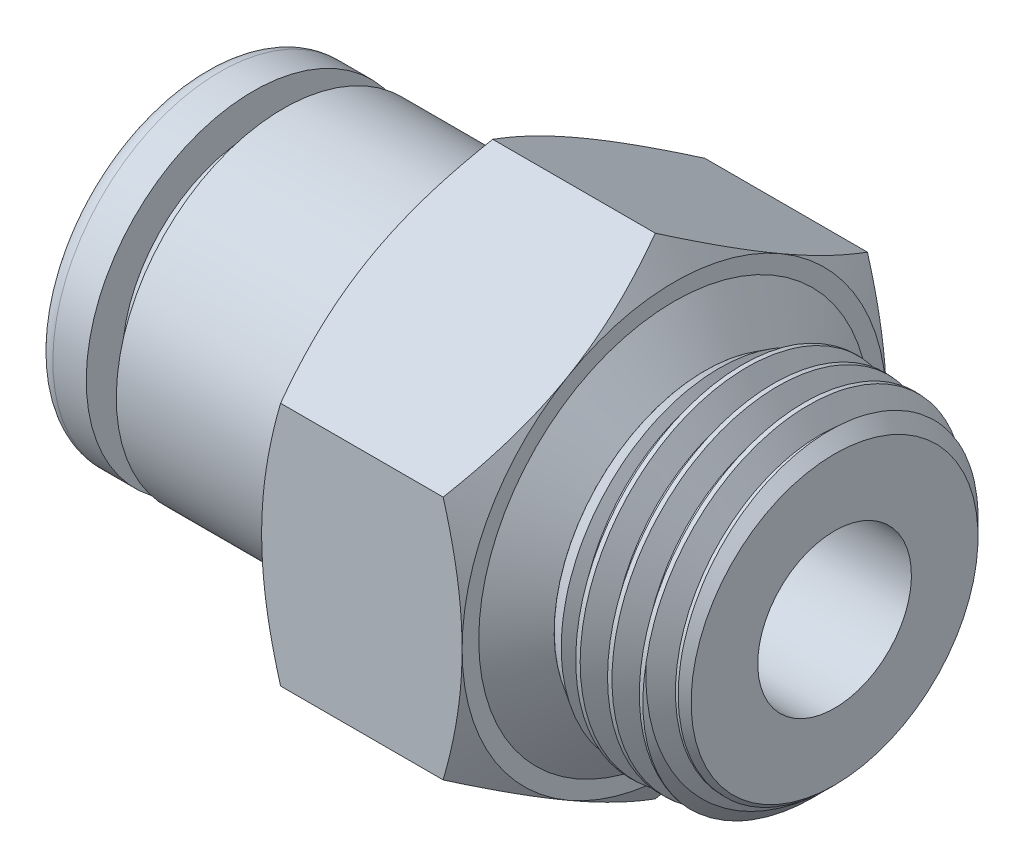
from build123d import *

# Parameters (mm, degrees)
SKETCH2_R              = 5.1435
EXTRUDE1_DEPTH         = 4.8
EXTRUDE1_TAPER         = 1.783333333
SKETCH5_OUTSIDE_W      = 26.658
SKETCH5_OUTSIDE_H      = 26.658
SKETCH5_OUTSIDE_R      = 4.294145567
EXTRUDE2_DEPTH         = 4.8
EXTRUDE2_DRAFT         = -45
CUT_SWEEP1_PITCH       = 0.924083939
CUT_SWEEP1_HEIGHT      = 5.723636364
CUT_SWEEP1_RADIUS      = 4.994051553
CUT_SWEEP1_START_ANGLE = -90
SKETCH6_R              = 5.1435
EXTRUDE3_DEPTH         = 3
EXTRUDE3_DRAFT         = -45
SKETCH7_R              = 2.3
EXTRUDE4_DEPTH         = 21.251448948
SKETCH8_R              = 5
EXTRUDE5_DEPTH         = 6
SKETCH9_OUTSIDE_W      = 40.902
SKETCH9_OUTSIDE_H      = 42.866
SKETCH9_OUTSIDE_R      = 6.35
EXTRUDE6_DEPTH         = 6
EXTRUDE6_DRAFT         = -60
SKETCH10_OUTSIDE_W     = 40.902
SKETCH10_OUTSIDE_H     = 42.866
SKETCH10_OUTSIDE_R     = 6.35
EXTRUDE7_DEPTH         = 6
EXTRUDE7_DRAFT         = -60


with BuildPart() as part:
    # Sketch1 → Revolve2 (revolve)
    with BuildSketch(Plane(origin=(0, 0, 0), x_dir=(-1, 0, 0), z_dir=(0, 0, -1)), mode=Mode.PRIVATE) as revolve2_sk:
        with BuildLine():
            Line((0, 4.5), (0, 3.675))
            ThreePointArc((0, 3.675), (-0.146446609, 3.321446609), (-0.5, 3.175))
            Line((-0.5, 3.175), (-9.45, 3.175))
            Line((-9.45, 3.175), (-9.45, 0))
            Line((-9.45, 0), (-14.1, 0))
            Line((-14.1, 0), (-14.1, 5))
            Line((-14.1, 5), (-2.4, 5))
            Line((-2.4, 5), (-2.4, 3.925))
            Line((-2.4, 3.925), (-1.5, 3.925))
            Line((-1.5, 3.925), (-1.5, 5))
            Line((-1.5, 5), (-0.5, 5))
            ThreePointArc((-0.5, 5), (-0.146446609, 4.853553391), (0, 4.5))
        make_face()
    revolve(revolve2_sk.sketch.rotate(Axis((0, 0, 0), (1, 0, 0)), 180), axis=Axis((0, 0, 0), (1, 0, 0)))


with BuildPart() as body_2:
    # Sketch2 → Extrude1 (new body)
    with BuildSketch(Plane(origin=(14.1, 0, 0), x_dir=(0, 0, -1), z_dir=(1, 0, 0))):
        Circle(SKETCH2_R)
    extrude(amount=EXTRUDE1_DEPTH, taper=EXTRUDE1_TAPER)


with BuildPart() as extrude2_tool:
    # Sketch5 outside → Extrude2 (with draft: the straight prism first)
    with BuildSketch(Plane(origin=(18.9, 0, 0), x_dir=(0, 0, -1), z_dir=(1, 0, 0))):
        Rectangle(SKETCH5_OUTSIDE_W, SKETCH5_OUTSIDE_H)
        Circle(SKETCH5_OUTSIDE_R, mode=Mode.SUBTRACT)
    extrude(amount=-EXTRUDE2_DEPTH)
    # Extrude2: the draft: its side faces are tilted about the plane it starts from
    extrude2_sides = [extrude2_tool.faces().sort_by_distance(p)[0] for p in [
        (16.5, -13.329, 0),
        (16.5, 0, -13.329),
        (16.5, 13.329, 0),
        (16.5, 0, 13.329),
        (16.5, 0, 4.294145567),
    ]]
    draft(extrude2_sides, Plane(origin=(18.9, 0, 0), x_dir=(0, 0, -1), z_dir=(1, 0, 0)), EXTRUDE2_DRAFT)


with BuildPart() as body_2_1:
    add(body_2.part)

    # Extrude2: cut by extrude2_tool
    add(extrude2_tool.part, mode=Mode.SUBTRACT)

    # Cut-Sweep1: sweep along a helix
    with BuildLine() as cut_sweep1_path:
        # a taper helix: rise per turn along the axis 0.923636364, along the cone's slant (build123d's pitch) 0.924083939
        add(Helix(CUT_SWEEP1_PITCH, CUT_SWEEP1_HEIGHT, CUT_SWEEP1_RADIUS, center=(18.9, 0, 0), direction=(-1, 0, 0), cone_angle=1.783333333, mode=Mode.PRIVATE).rotate(Axis((18.9, 0, 0), (-1, 0, 0)), CUT_SWEEP1_START_ANGLE))
    # Sketch4 → Cut-Sweep1 (sweep, cut)
    with BuildSketch(Plane(origin=(0, 0, 0), x_dir=(-1, 0, 0), z_dir=(0, 0, -1))):
        Polygon((-19.361818182, 4.394132137), (-19.246363636, 4.394132137), (-18.842272727, 5.094038122), (-19.708181818, 4.994051553), align=None)
    sweep(path=cut_sweep1_path.line, is_frenet=True, mode=Mode.SUBTRACT)

    # Sketch5.5 → Cut-Revolve1 (revolve, cut)
    with BuildSketch(Plane.XY, mode=Mode.PRIVATE) as cut_revolve1_sk:
        Polygon((14.1, -5.1435), (15.023189005, -5.114756424), (15.94637801, -5.086012849), (15.023189005, -4.514837008), (14.1, -4.543580584), align=None)
    revolve(cut_revolve1_sk.sketch.rotate(Axis((14.1, 0, 0), (1, 0, 0)), 159.331882944), axis=Axis((14.1, 0, 0), (1, 0, 0)), mode=Mode.SUBTRACT)


with BuildPart() as extrude3_tool:
    # Sketch6 → Extrude3 (with draft: the straight prism first)
    with BuildSketch(Plane(origin=(14.1, 0, 0), x_dir=(0, 0, -1), z_dir=(1, 0, 0))):
        Circle(SKETCH6_R)
    extrude(amount=-EXTRUDE3_DEPTH)
    # Extrude3: the draft: its side faces are tilted about the plane it starts from
    extrude3_sides = [extrude3_tool.faces().sort_by_distance(p)[0] for p in [
        (12.6, 0, 5.1435),
    ]]
    draft(extrude3_sides, Plane(origin=(14.1, 0, 0), x_dir=(0, 0, -1), z_dir=(1, 0, 0)), EXTRUDE3_DRAFT)


with BuildPart() as part_1:
    add(part.part)

    # Extrude3: add extrude3_tool
    add(extrude3_tool.part)

    add(body_2_1.part)  # Extrude3 merges body 2

    # Sketch7 → Extrude4 (cut, through all)
    with BuildSketch(Plane(origin=(18.9, 0, 0), x_dir=(0, 0, -1), z_dir=(1, 0, 0))):
        with Locations(Location((0, 0, 0), (0, 0, 90))):
            Circle(SKETCH7_R)
    extrude(amount=-EXTRUDE4_DEPTH, mode=Mode.SUBTRACT)

    # Sketch8 → Extrude5 (add)
    with BuildSketch(Plane(origin=(14.1, 0, 0), x_dir=(0, 0, -1), z_dir=(1, 0, 0))):
        Polygon((0, 7.332348419), (-6.35, 3.666174209), (-6.35, -3.666174209), (0, -7.332348419), (6.35, -3.666174209), (6.35, 3.666174209), align=None)
        with Locations(Location((0, 0, 0), (0, 0, 270))):
            Circle(SKETCH8_R, mode=Mode.SUBTRACT)
    extrude(amount=-EXTRUDE5_DEPTH)


with BuildPart() as extrude6_tool:
    # Sketch9 outside → Extrude6 (with draft: the straight prism first)
    with BuildSketch(Plane(origin=(14.1, 0, 0), x_dir=(0, 0, -1), z_dir=(1, 0, 0))):
        Rectangle(SKETCH9_OUTSIDE_W, SKETCH9_OUTSIDE_H)
        Circle(SKETCH9_OUTSIDE_R, mode=Mode.SUBTRACT)
    extrude(amount=-EXTRUDE6_DEPTH)
    # Extrude6: the draft: its side faces are tilted about the plane it starts from
    extrude6_sides = [extrude6_tool.faces().sort_by_distance(p)[0] for p in [
        (11.1, -21.433, 0),
        (11.1, 0, -20.451),
        (11.1, 21.433, 0),
        (11.1, 0, 20.451),
        (11.1, 0, 6.35),
    ]]
    draft(extrude6_sides, Plane(origin=(14.1, 0, 0), x_dir=(0, 0, -1), z_dir=(1, 0, 0)), EXTRUDE6_DRAFT)


with BuildPart() as part_2:
    add(part_1.part)

    # Extrude6: cut by extrude6_tool
    add(extrude6_tool.part, mode=Mode.SUBTRACT)


with BuildPart() as extrude7_tool:
    # Sketch10 outside → Extrude7 (with draft: the straight prism first)
    with BuildSketch(Plane.ZY.offset(-8.1)):
        Rectangle(SKETCH10_OUTSIDE_W, SKETCH10_OUTSIDE_H)
        Circle(SKETCH10_OUTSIDE_R, mode=Mode.SUBTRACT)
    extrude(amount=-EXTRUDE7_DEPTH)
    # Extrude7: the draft: its side faces are tilted about the plane it starts from
    extrude7_sides = [extrude7_tool.faces().sort_by_distance(p)[0] for p in [
        (11.1, -21.433, 0),
        (11.1, 0, 20.451),
        (11.1, 21.433, 0),
        (11.1, 0, -20.451),
        (11.1, 0, -6.35),
    ]]
    draft(extrude7_sides, Plane.ZY.offset(-8.1), EXTRUDE7_DRAFT)


with BuildPart() as part_3:
    add(part_2.part)

    # Extrude7: cut by extrude7_tool
    add(extrude7_tool.part, mode=Mode.SUBTRACT)


with BuildPart() as body_2_2:
    # Sketch12 → Revolve3 (revolve)
    with BuildSketch(Plane.XY):
        Polygon((14.1, -5.1435), (14.1, -5.851559397), (15.023189005, -4.514837008), (14.523431178, -4.530397015), align=None)
    revolve(axis=Axis((0, 0, 0), (1, 0, 0)))


solid = Compound([part_3.part, body_2_2.part])
